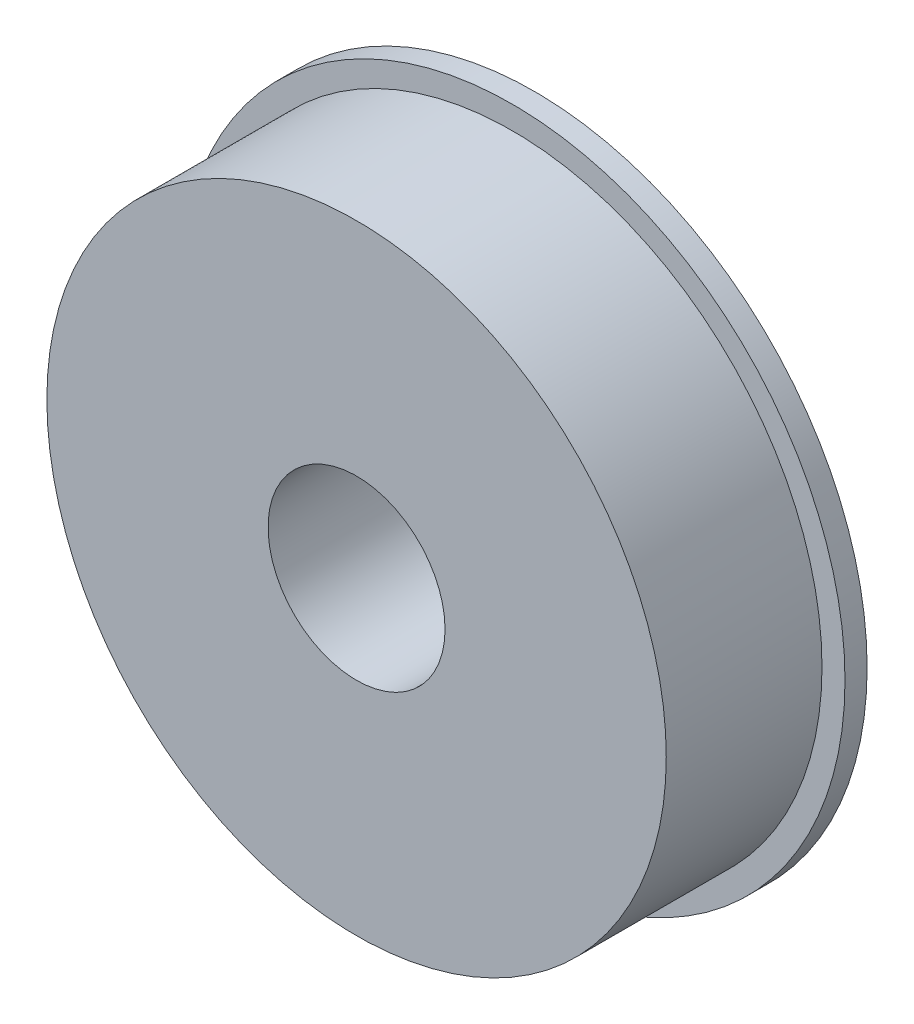
from build123d import *

# Parameters (mm, degrees)
SKETCH2_R           = 23.876
BOSS_EXTRUDE1_DEPTH = 1.5875
SKETCH3_R           = 22.225
BOSS_EXTRUDE2_DEPTH = 11.176
SKETCH4_R           = 6.35
CUT_EXTRUDE1_DEPTH  = 10.668


with BuildPart() as part:
    # Sketch2 → Boss-Extrude1 (new body)
    with BuildSketch(Plane.XY):
        Circle(SKETCH2_R)
    extrude(amount=BOSS_EXTRUDE1_DEPTH)

    # Sketch3 → Boss-Extrude2 (add)
    with BuildSketch(Plane.XY.offset(1.5875)):
        Circle(SKETCH3_R)
    extrude(amount=BOSS_EXTRUDE2_DEPTH)

    # Sketch4 → Cut-Extrude1 (cut)
    with BuildSketch(Plane.XY.offset(12.7635)):
        Circle(SKETCH4_R)
    extrude(amount=-CUT_EXTRUDE1_DEPTH, mode=Mode.SUBTRACT)


solid = part.part
